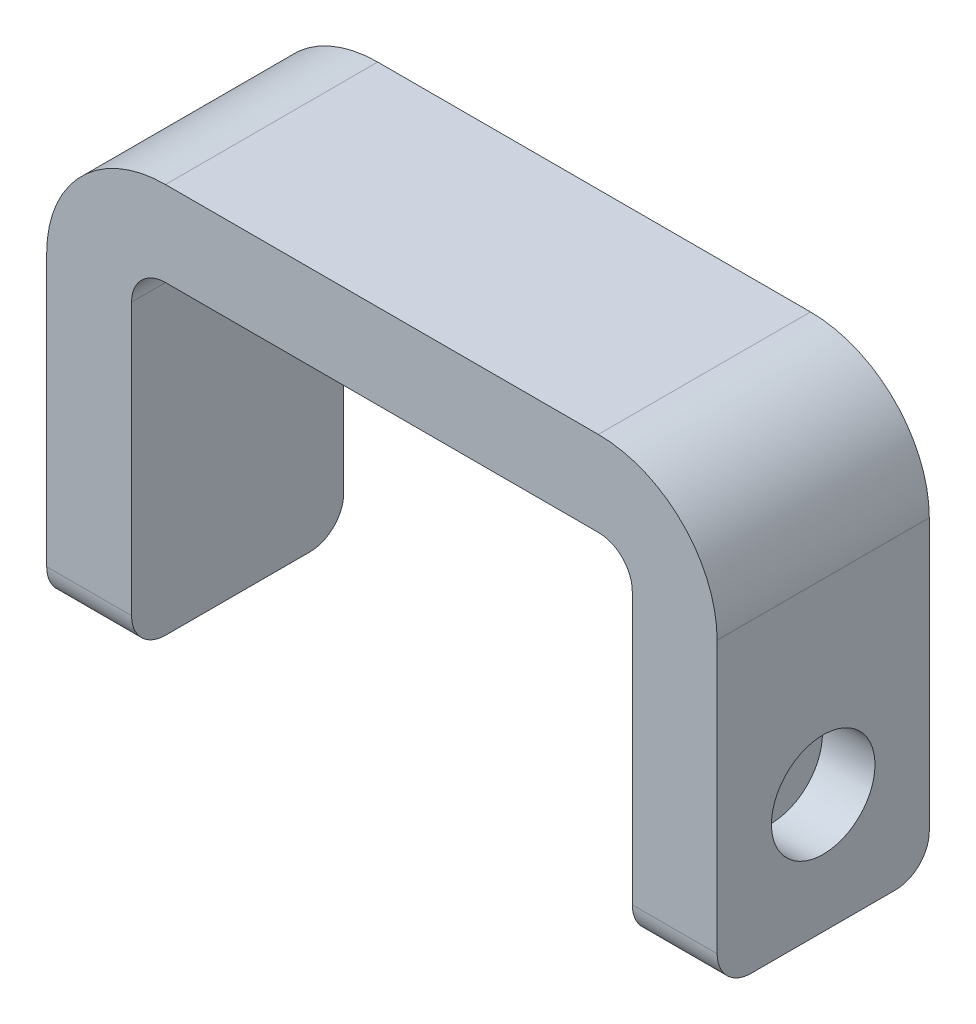
from build123d import *

# Parameters (mm, degrees)
BOSS_EXTRUDE1_DEPTH = 6.25
SKETCH2_R           = 3.05
CUT_EXTRUDE1_DEPTH  = 3.1
FILLET1_R           = 2
FILLET2_R           = 7
FILLET3_R           = 2


with BuildPart() as part:
    # Sketch1 → Boss-Extrude1 (new body, symmetric)
    with BuildSketch(Plane.XY):
        Polygon((-14.75, 0), (-19.75, 0), (-19.75, 25), (19.75, 25), (19.75, 0), (14.75, 0), (14.75, 20), (-14.75, 20), align=None)
    extrude(amount=BOSS_EXTRUDE1_DEPTH, both=True)

    # Sketch2 → Cut-Extrude1 (cut)
    with BuildSketch(Plane.ZY.offset(19.75)):
        with Locations((0, 7)):
            Circle(SKETCH2_R)
    cut_extrude1 = extrude(amount=-CUT_EXTRUDE1_DEPTH, mode=Mode.SUBTRACT)

    # Mirror1: Cut-Extrude1 across plane
    add(cut_extrude1.mirror(Plane(origin=(0, 0, 0), x_dir=(0, 0, 1), z_dir=(1, 0, 0))), mode=Mode.SUBTRACT)

    # Fillet1
    fillet1_edges = [part.edges().sort_by_distance(p)[0] for p in [
        (14.75, 20, 0),
        (-14.75, 20, 0),
    ]]
    fillet(fillet1_edges, radius=FILLET1_R)

    # Fillet2
    fillet2_edges = [part.edges().sort_by_distance(p)[0] for p in [
        (-19.75, 25, 0),
        (19.75, 25, 0),
    ]]
    fillet(fillet2_edges, radius=FILLET2_R)

    # Fillet3
    fillet3_edges = [part.edges().sort_by_distance(p)[0] for p in [
        (17.25, 0, -6.25),
        (17.25, 0, 6.25),
        (-17.25, 0, 6.25),
        (-17.25, 0, -6.25),
    ]]
    fillet(fillet3_edges, radius=FILLET3_R)


solid = part.part
